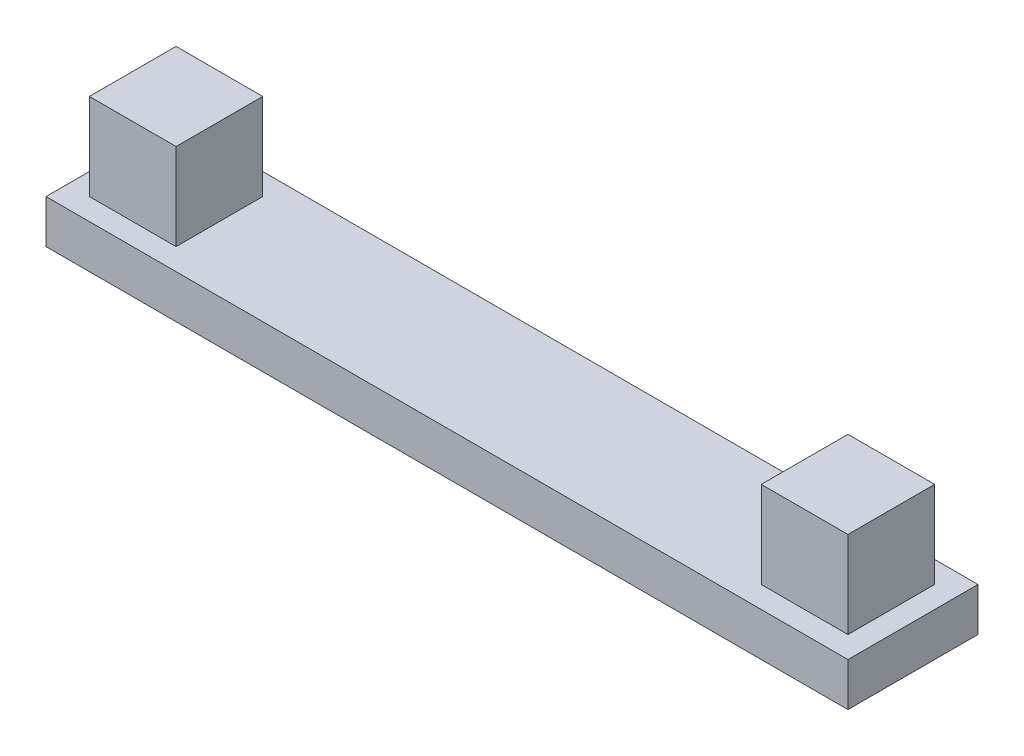
from build123d import *

# Parameters (mm, degrees)
SKETCH1_W           = 18.5
SKETCH1_H           = 3
SKETCH1_W_2         = 2
SKETCH1_H_2         = 2
BOSS_EXTRUDE1_DEPTH = 1
SKETCH1_3_W         = 2
SKETCH1_3_H         = 2
BOSS_EXTRUDE2_DEPTH = 3


with BuildPart() as part:
    # Sketch1 → Boss-Extrude1 (new body)
    with BuildSketch(Plane(origin=(0, 0, 0), x_dir=(1, 0, 0), z_dir=(0, 1, 0))):
        with Locations((9.25, 1.5)):
            Rectangle(SKETCH1_W, SKETCH1_H)
        with Locations((1.5, 1.5)):
            Rectangle(SKETCH1_W_2, SKETCH1_H_2, mode=Mode.SUBTRACT)
        with Locations((17, 1.5)):
            Rectangle(SKETCH1_W_2, SKETCH1_H_2, mode=Mode.SUBTRACT)
    extrude(amount=BOSS_EXTRUDE1_DEPTH)

    # Sketch1_3 → Boss-Extrude2 (add)
    with BuildSketch(Plane(origin=(0, 0, 0), x_dir=(1, 0, 0), z_dir=(0, 1, 0))):
        with Locations((1.5, 1.5)):
            Rectangle(SKETCH1_3_W, SKETCH1_3_H)
        with Locations((17, 1.5)):
            Rectangle(SKETCH1_3_W, SKETCH1_3_H)
    extrude(amount=BOSS_EXTRUDE2_DEPTH)


solid = part.part
